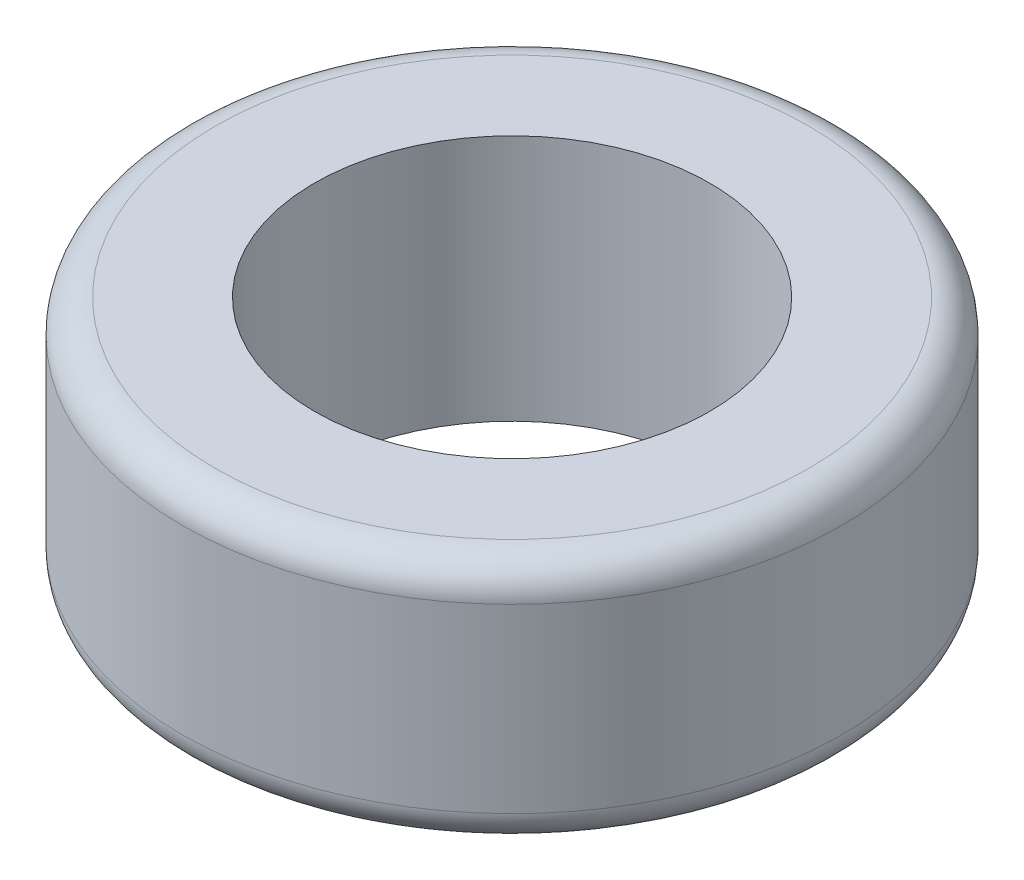
from build123d import *

# Parameters (mm, degrees)
SKETCH1_R           = 10
SKETCH1_R_2         = 6
BOSS_EXTRUDE1_DEPTH = 7.5
FILLET1_R           = 1


with BuildPart() as part:
    # Sketch1 → Boss-Extrude1 (new body)
    with BuildSketch(Plane(origin=(0, 0, 0), x_dir=(1, 0, 0), z_dir=(0, 1, 0))):
        Circle(SKETCH1_R)
        Circle(SKETCH1_R_2, mode=Mode.SUBTRACT)
    extrude(amount=BOSS_EXTRUDE1_DEPTH)

    # Fillet1
    fillet1_edges = [part.edges().sort_by_distance(p)[0] for p in [
        (-10, 0, 0),
        (-10, 7.5, 0),
    ]]
    fillet(fillet1_edges, radius=FILLET1_R)


solid = part.part
